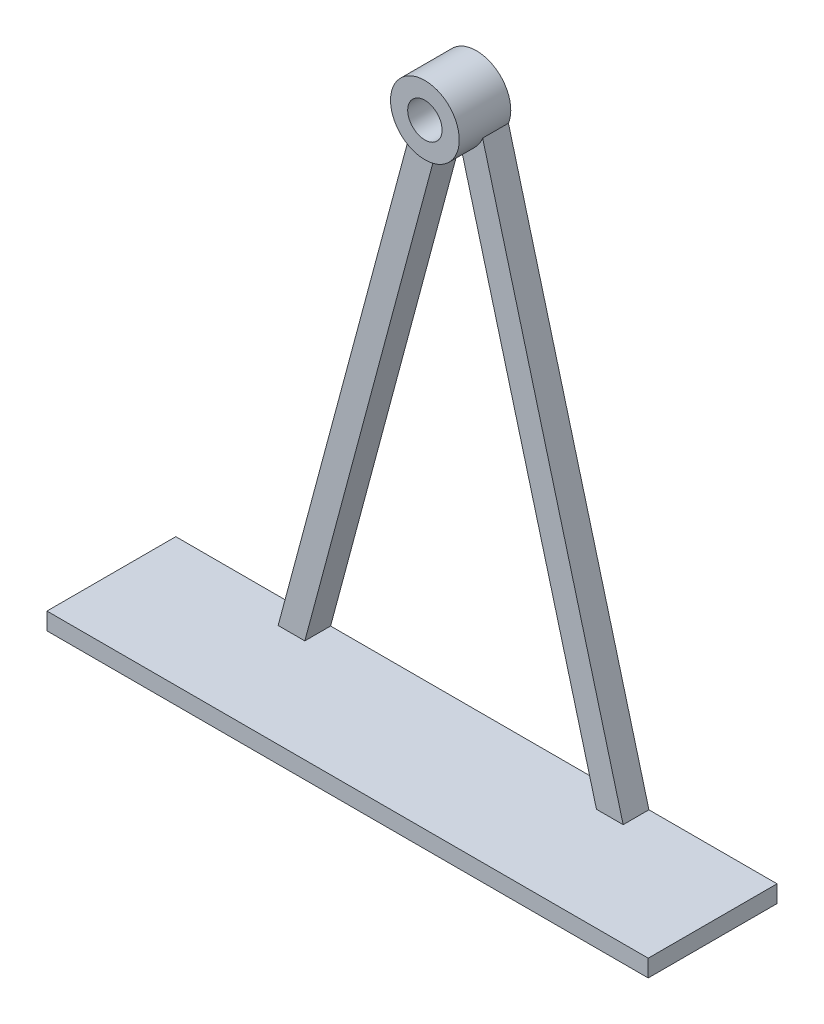
from build123d import *

# Parameters (mm, degrees)
SKETCH_3_R         = 8
SKETCH_3_R_2       = 4
EXTRUDE_716_DEPTH  = 12
EXTRUDE_1137_DEPTH = 6
SKETCH_7_W         = 140
SKETCH_7_H         = 30
EXTRUDE_1364_DEPTH = 4


with BuildPart() as part:
    # 草图3 → Extrude 716 (new body)
    with BuildSketch(Plane.XY):
        Circle(SKETCH_3_R)
        Circle(SKETCH_3_R_2, mode=Mode.SUBTRACT)
    extrude(amount=EXTRUDE_716_DEPTH)

    # 草图6 → Extrude 1137 (add)
    with BuildSketch(Plane.XY):
        with BuildLine():
            Line((-40.169068564, -125), (-33.957411481, -125))
            Line((-33.957411481, -125), (-2.5, -7.599342077))
            ThreePointArc((-2.5, -7.599342077), (-5.502602373, -5.807010171), (-7.45385736, -2.905169608))
            Line((-7.45385736, -2.905169608), (-40.169068564, -125))
        make_face()
    extrude_1137 = extrude(amount=EXTRUDE_1137_DEPTH)

    # Mirror 1200: Extrude 1137 across plane
    add(extrude_1137.mirror(Plane(origin=(0, 0, 0), x_dir=(0, 0, 1), z_dir=(1, 0, 0))))

    # 草图7 → Extrude 1364 (add)
    with BuildSketch(Plane.XZ.offset(125)):
        with Locations((0, 15)):
            Rectangle(SKETCH_7_W, SKETCH_7_H)
    extrude(amount=EXTRUDE_1364_DEPTH)


solid = part.part
